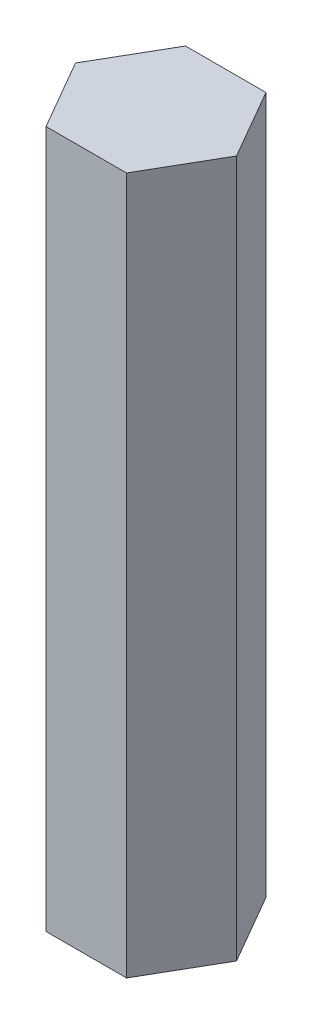
from build123d import *

# Parameters (mm, degrees)
BOSS_EXTRUDE1_DEPTH = 40


with BuildPart() as part:
    # Sketch1 → Boss-Extrude1 (new body)
    with BuildSketch(Plane(origin=(0, 0, 0), x_dir=(1, 0, 0), z_dir=(0, 1, 0))):
        Polygon((4.618802154, 0), (2.309401077, 4), (-2.309401077, 4), (-4.618802154, 0), (-2.309401077, -4), (2.309401077, -4), align=None)
    extrude(amount=BOSS_EXTRUDE1_DEPTH)


solid = part.part
